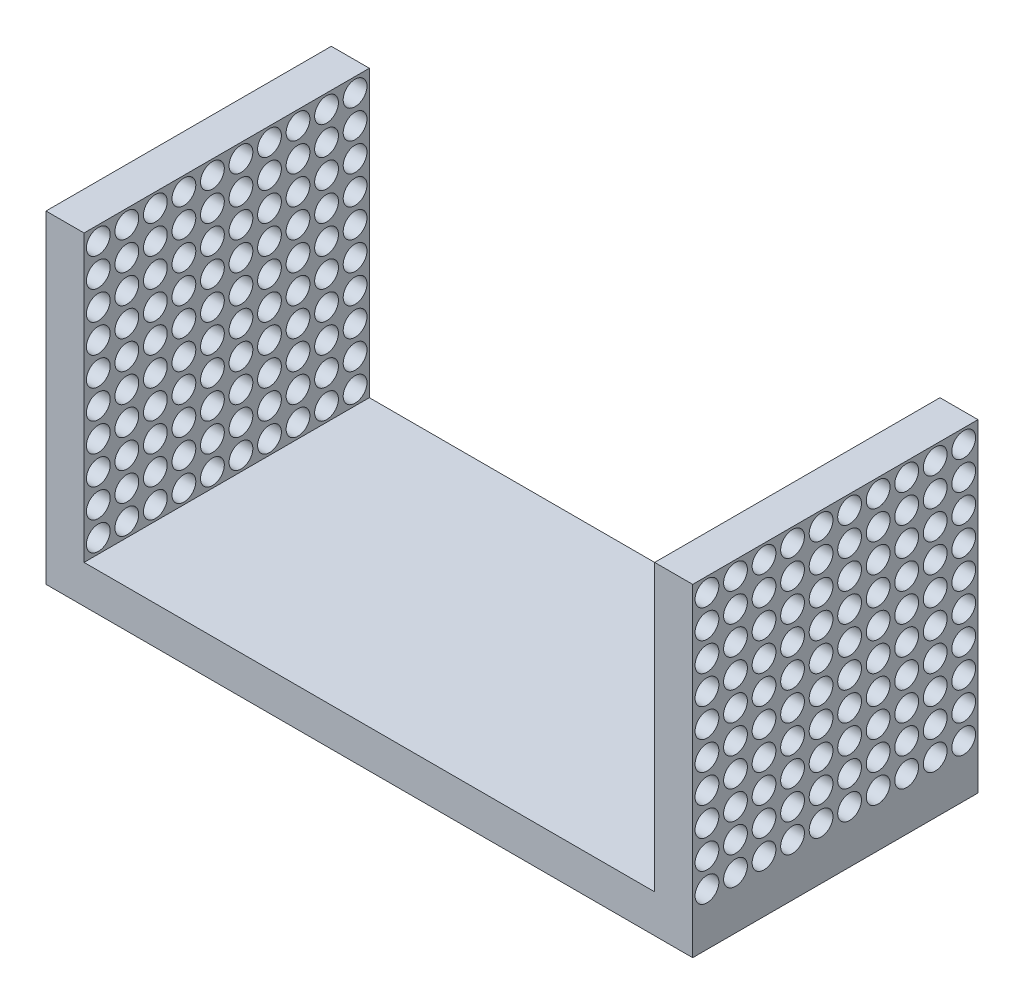
from build123d import *

# Parameters (mm, degrees)
SKETCH1_W                = 34
SKETCH1_H                = 17
BOSS_EXTRUDE1_DEPTH      = 7.5
BOSS_EXTRUDE1_DEPTH_BACK = 7.5
SKETCH2_W                = 30
SKETCH2_H                = 15
CUT_EXTRUDE1_DEPTH       = 15
SKETCH3_R                = 0.625
CUT_EXTRUDE2_DEPTH       = 34
LPATTERN1_COUNT          = 10
LPATTERN1_PITCH          = 1.5
LPATTERN1_COUNT_DIR2     = 10
LPATTERN1_PITCH_DIR2     = 1.5


with BuildPart() as part:
    # Sketch1 → Boss-Extrude1 (new body, two sides)
    with BuildSketch(Plane.XY) as boss_extrude1_sk:
        Rectangle(SKETCH1_W, SKETCH1_H)
    extrude(amount=BOSS_EXTRUDE1_DEPTH)
    extrude(boss_extrude1_sk.sketch, amount=-BOSS_EXTRUDE1_DEPTH_BACK)

    # Sketch2 → Cut-Extrude1 (cut)
    with BuildSketch(Plane.XY.offset(7.5)):
        with Locations((0, 1)):
            Rectangle(SKETCH2_W, SKETCH2_H)
    extrude(amount=-CUT_EXTRUDE1_DEPTH, mode=Mode.SUBTRACT)

    # Sketch3 → Cut-Extrude2 (cut)
    with BuildSketch(Plane(origin=(17, 0, 0), x_dir=(0, 0, -1), z_dir=(1, 0, 0))):
        with Locations((-6.75, 7.75)):
            Circle(SKETCH3_R)
    cut_extrude2 = extrude(amount=-CUT_EXTRUDE2_DEPTH, mode=Mode.SUBTRACT)

    # LPattern1: Cut-Extrude2 10 × 10
    with Locations(*[(0, -j * LPATTERN1_PITCH_DIR2, -i * LPATTERN1_PITCH) for i in range(LPATTERN1_COUNT) for j in range(LPATTERN1_COUNT_DIR2) if (i, j) != (0, 0)]):
        add(cut_extrude2, mode=Mode.SUBTRACT)


solid = part.part
